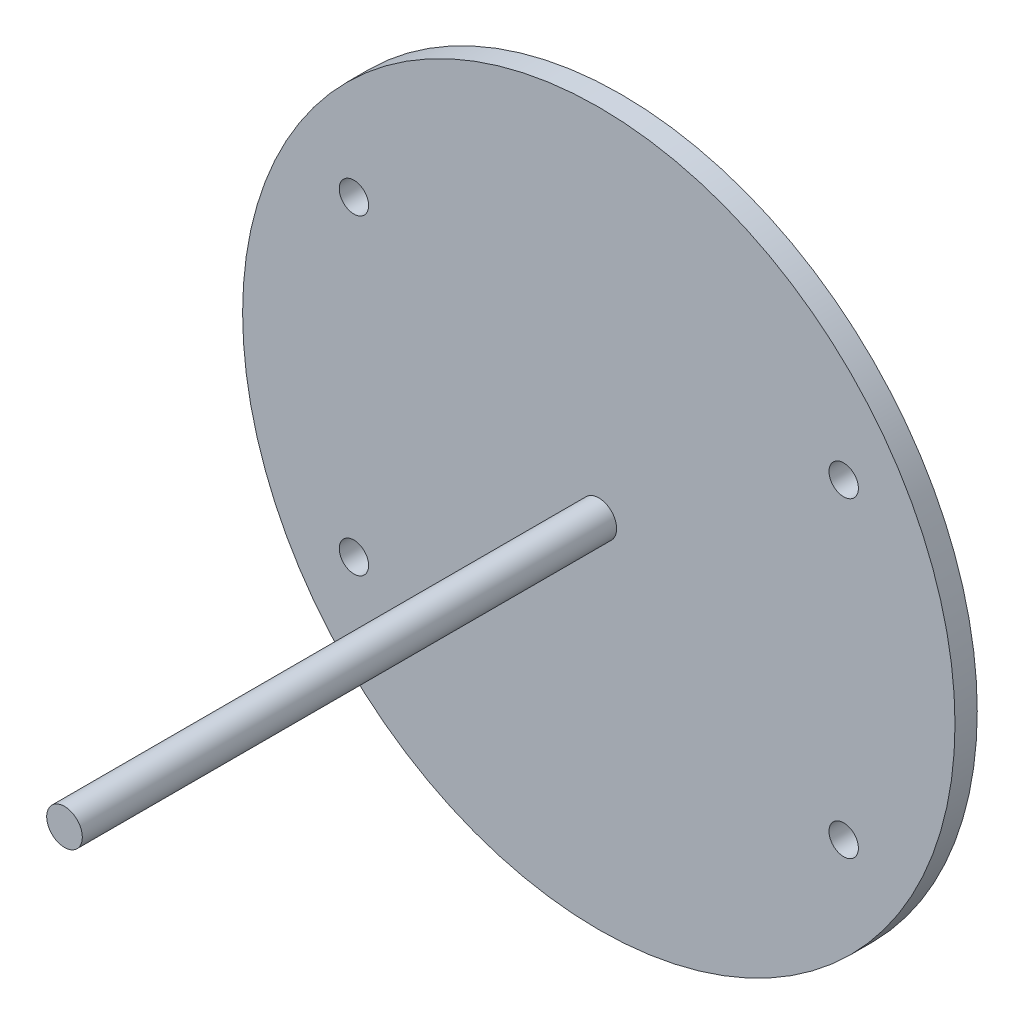
from build123d import *

# Parameters (mm, degrees)
SKETCH_1_R      = 40
SKETCH_1_R_2    = 1.65
EXTRUDE_1_DEPTH = 2.5
SKETCH_2_R      = 2
EXTRUDE_2_DEPTH = 60


with BuildPart() as part:
    # 草图1 → 凸台-拉伸1 (new body)
    with BuildSketch(Plane.XY):
        Circle(SKETCH_1_R)
        with Locations((-27.5, 17.5)):
            Circle(SKETCH_1_R_2, mode=Mode.SUBTRACT)
        with Locations((27.5, 17.5)):
            Circle(SKETCH_1_R_2, mode=Mode.SUBTRACT)
        with Locations((27.5, -17.5)):
            Circle(SKETCH_1_R_2, mode=Mode.SUBTRACT)
        with Locations((-27.5, -17.5)):
            Circle(SKETCH_1_R_2, mode=Mode.SUBTRACT)
    extrude(amount=EXTRUDE_1_DEPTH)

    # 草图2 → 凸台-拉伸2 (add)
    with BuildSketch(Plane.XY.offset(2.5)):
        Circle(SKETCH_2_R)
    extrude(amount=EXTRUDE_2_DEPTH)


solid = part.part
